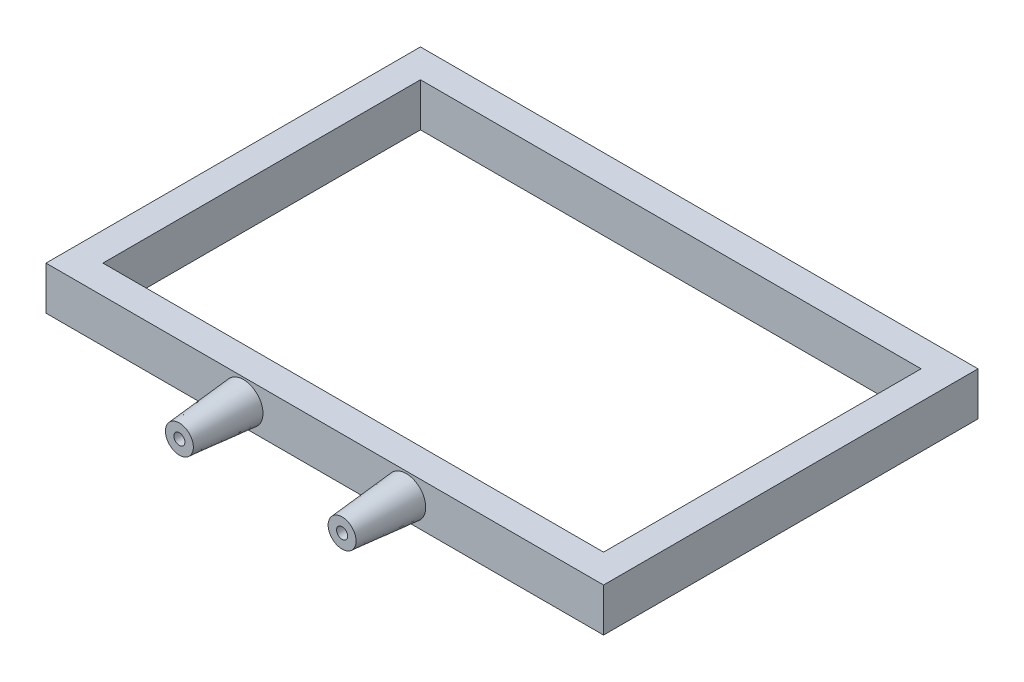
from build123d import *

# Parameters (mm, degrees)
SKETCH_1_W          = 156.75
SKETCH_1_H          = 105.271994628
EXTRUDE_1_DEPTH     = 12.2
SKETCH_2_W          = 7.639581741
SKETCH_2_H          = 13.89014237
CUT_EXTRUDE_1_DEPTH = 6.1
SKETCH_4_R          = 5.5
EXTRUDE_2_DEPTH     = 18
EXTRUDE_2_TAPER     = 5
CUT_EXTRUDE_2_REACH = 20
SKETCH_6_R          = 1.55
SKETCH_7_W          = 7
SKETCH_7_H          = 3.5
CUT_EXTRUDE_3_DEPTH = 9.1
SKETCH_8_W          = 140.75
SKETCH_8_H          = 89.271994628
CUT_EXTRUDE_4_DEPTH = 13.2


with BuildPart() as part:
    # ｽｹｯﾁ1 → ﾎﾞｽ - 押し出し1 (new body)
    with BuildSketch(Plane(origin=(0, 0, 0), x_dir=(1, 0, 0), z_dir=(0, 1, 0))):
        Rectangle(SKETCH_1_W, SKETCH_1_H)
    extrude(amount=EXTRUDE_1_DEPTH)

    # ｽｹｯﾁ2 → ｶｯﾄ - 押し出し1 (cut)
    with BuildSketch(Plane(origin=(0, 12.2, 0), x_dir=(1, 0, 0), z_dir=(0, 1, 0))):
        with BuildLine():
            ThreePointArc((-44.016, 13.890145056), (-40.196209129, 16.500447871), (-36.376418259, 13.890145056))
            Line((-36.376418259, 13.890145056), (-44.016, 13.890145056))
        make_face()
        with Locations((-40.19620913, 6.945073871)):
            Rectangle(SKETCH_2_W, SKETCH_2_H)
        with BuildLine():
            Line((-44.016, 2.686e-06), (-36.376418259, 2.686e-06))
            ThreePointArc((-36.376418259, 2.686e-06), (-40.196209129, -2.610300128), (-44.016, 2.686e-06))
        make_face()
        with BuildLine():
            Line((44.016, 13.890145056), (36.376418259, 13.890145056))
            ThreePointArc((36.376418259, 13.890145056), (40.196209129, 16.500447871), (44.016, 13.890145056))
        make_face()
        with Locations((40.19620913, 6.945073871)):
            Rectangle(SKETCH_2_W, SKETCH_2_H)
        with BuildLine():
            ThreePointArc((44.016, 2.686e-06), (40.196209129, -2.610300128), (36.376418259, 2.686e-06))
            Line((36.376418259, 2.686e-06), (44.016, 2.686e-06))
        make_face()
    extrude(amount=-CUT_EXTRUDE_1_DEPTH, mode=Mode.SUBTRACT)

    # ｽｹｯﾁ4 → ﾎﾞｽ - 押し出し2 (add)
    with BuildSketch(Plane.XY.offset(52.635997314)):
        with Locations((-22.875, 6.1)):
            Circle(SKETCH_4_R)
        with Locations((22.875, 6.1)):
            Circle(SKETCH_4_R)
    extrude(amount=EXTRUDE_2_DEPTH, taper=EXTRUDE_2_TAPER)

    # ｽｹｯﾁ6 → ｶｯﾄ - 押し出し2 (cut, up to next)
    with BuildSketch(Plane.XY.offset(52.635997314), mode=Mode.PRIVATE) as cut_extrude_2_sk1:
        with Locations((-22.875, 6.1)):
            Circle(SKETCH_6_R)
    cut_extrude_2_tool1 = extrude(cut_extrude_2_sk1.sketch, amount=CUT_EXTRUDE_2_REACH, mode=Mode.PRIVATE) & part.part
    add(cut_extrude_2_tool1.solids().sort_by_distance((-22.875, 6.1, 52.635997))[0], mode=Mode.SUBTRACT)
    # ｽｹｯﾁ6 → ｶｯﾄ - 押し出し2 (cut, up to next)
    with BuildSketch(Plane.XY.offset(52.635997314), mode=Mode.PRIVATE) as cut_extrude_2_sk2:
        with Locations((22.875, 6.1)):
            Circle(SKETCH_6_R)
    cut_extrude_2_tool2 = extrude(cut_extrude_2_sk2.sketch, amount=CUT_EXTRUDE_2_REACH, mode=Mode.PRIVATE) & part.part
    add(cut_extrude_2_tool2.solids().sort_by_distance((22.875, 6.1, 52.635997))[0], mode=Mode.SUBTRACT)

    # ｽｹｯﾁ7 → ｶｯﾄ - 押し出し3 (cut)
    with BuildSketch(Plane(origin=(0, 0, 0), x_dir=(1, 0, 0), z_dir=(0, 1, 0))):
        with Locations((-22.875, -58.885997314)):
            Rectangle(SKETCH_7_W, SKETCH_7_H)
        with Locations((22.875, -58.885997314)):
            Rectangle(SKETCH_7_W, SKETCH_7_H)
    extrude(amount=CUT_EXTRUDE_3_DEPTH, mode=Mode.SUBTRACT)

    # ｽｹｯﾁ8 → ｶｯﾄ - 押し出し4 (cut, through all)
    with BuildSketch(Plane(origin=(0, 0, 0), x_dir=(-1, 0, 0), z_dir=(0, -1, 0))):
        Rectangle(SKETCH_8_W, SKETCH_8_H)
    extrude(amount=-CUT_EXTRUDE_4_DEPTH, mode=Mode.SUBTRACT)


solid = part.part
